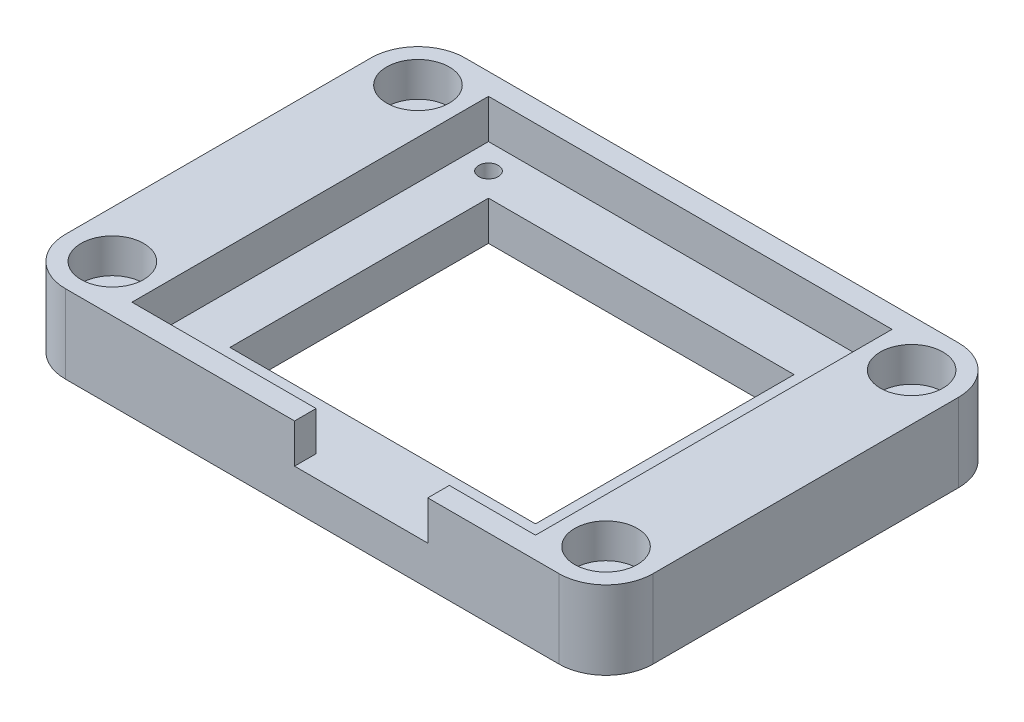
from build123d import *

# Parameters (mm, degrees)
SKETCH_1_W                   = 75
SKETCH_1_H                   = 51
EXTRUDE_1_DEPTH              = 10
SKETCH_2_W                   = 51.5
SKETCH_2_H                   = 45.5
CUT_EXTRUDE_1_DEPTH          = 5
SKETCH_3_R                   = 1.25
CUT_EXTRUDE_2_DEPTH          = 5
CUT_EXTRUDE_3_REACH          = 7
SKETCH_4_W                   = 39
SKETCH_4_H                   = 33
FILLET_1_R                   = 6
CUT_EXTRUDE_4_DEPTH          = 2
HOLE_WIZARD_M4_1_D           = 4.5
HOLE_WIZARD_M4_1_CBORE_D     = 8
HOLE_WIZARD_M4_1_CBORE_DEPTH = 4.4
SKETCH_7_W                   = 17
SKETCH_7_H                   = 2.75
CUT_EXTRUDE_5_DEPTH          = 5


with BuildPart() as part:
    # 草图1 → 凸台-拉伸1 (new body)
    with BuildSketch(Plane(origin=(0, 0, 0), x_dir=(1, 0, 0), z_dir=(0, 1, 0))):
        Rectangle(SKETCH_1_W, SKETCH_1_H)
    extrude(amount=EXTRUDE_1_DEPTH)

    # 草图2 → 切除-拉伸1 (cut)
    with BuildSketch(Plane(origin=(0, 10, 0), x_dir=(1, 0, 0), z_dir=(0, 1, 0))):
        Rectangle(SKETCH_2_W, SKETCH_2_H)
    extrude(amount=-CUT_EXTRUDE_1_DEPTH, mode=Mode.SUBTRACT)

    # 草图3 → 切除-拉伸2 (cut)
    with BuildSketch(Plane(origin=(0, 5, 0), x_dir=(1, 0, 0), z_dir=(0, 1, 0))):
        with Locations((-22.5, 19.5)):
            Circle(SKETCH_3_R)
        with Locations((-22.5, -19.5)):
            Circle(SKETCH_3_R)
        with Locations((22.5, -19.5)):
            Circle(SKETCH_3_R)
        with Locations((22.5, 19.5)):
            Circle(SKETCH_3_R)
    extrude(amount=-CUT_EXTRUDE_2_DEPTH, mode=Mode.SUBTRACT)

    # 草图4 → 切除-拉伸3 (cut, up to next)
    with BuildSketch(Plane(origin=(0, 5, 0), x_dir=(1, 0, 0), z_dir=(0, 1, 0)), mode=Mode.PRIVATE) as cut_extrude_3_sk1:
        Rectangle(SKETCH_4_W, SKETCH_4_H)
    cut_extrude_3_tool1 = extrude(cut_extrude_3_sk1.sketch, amount=-CUT_EXTRUDE_3_REACH, mode=Mode.PRIVATE) & part.part
    add(cut_extrude_3_tool1.solids().sort_by_distance((0, 5, 0))[0], mode=Mode.SUBTRACT)

    # 圆角1
    fillet_1_edges = [part.edges().sort_by_distance(p)[0] for p in [
        (37.5, 5, 25.5),
        (-37.5, 5, 25.5),
        (-37.5, 5, -25.5),
        (37.5, 5, -25.5),
    ]]
    fillet(fillet_1_edges, radius=FILLET_1_R)

    # 草图5 → 切除-拉伸4 (cut)
    with BuildSketch(Plane.XZ):
        Polygon((-19.324573519, 19.5), (-20.91228676, 22.25), (-24.08771324, 22.25), (-25.675426481, 19.5), (-24.08771324, 16.75), (-20.91228676, 16.75), align=None)
        Polygon((25.675426481, 19.5), (24.08771324, 22.25), (20.91228676, 22.25), (19.324573519, 19.5), (20.91228676, 16.75), (24.08771324, 16.75), align=None)
        Polygon((-19.324573519, -19.5), (-20.91228676, -16.75), (-24.08771324, -16.75), (-25.675426481, -19.5), (-24.08771324, -22.25), (-20.91228676, -22.25), align=None)
        Polygon((25.675426481, -19.5), (24.08771324, -16.75), (20.91228676, -16.75), (19.324573519, -19.5), (20.91228676, -22.25), (24.08771324, -22.25), align=None)
    extrude(amount=-CUT_EXTRUDE_4_DEPTH, mode=Mode.SUBTRACT)

    # M4 六角凹头螺钉的柱形沉头孔1 (through all)
    with Locations(Plane(origin=(31.5, 10, 19.5), x_dir=(0, 0, 1), z_dir=(0, 1, 0))):
        with Locations((0, 0), (-39, 0), (-39, -63), (0, -63)):
            CounterBoreHole(HOLE_WIZARD_M4_1_D / 2, HOLE_WIZARD_M4_1_CBORE_D / 2, HOLE_WIZARD_M4_1_CBORE_DEPTH)

    # 草图7 → 切除-拉伸5 (cut)
    with BuildSketch(Plane(origin=(0, 10, 0), x_dir=(1, 0, 0), z_dir=(0, 1, 0))):
        with Locations((6.25, -24.125)):
            Rectangle(SKETCH_7_W, SKETCH_7_H)
    extrude(amount=-CUT_EXTRUDE_5_DEPTH, mode=Mode.SUBTRACT)


solid = part.part
